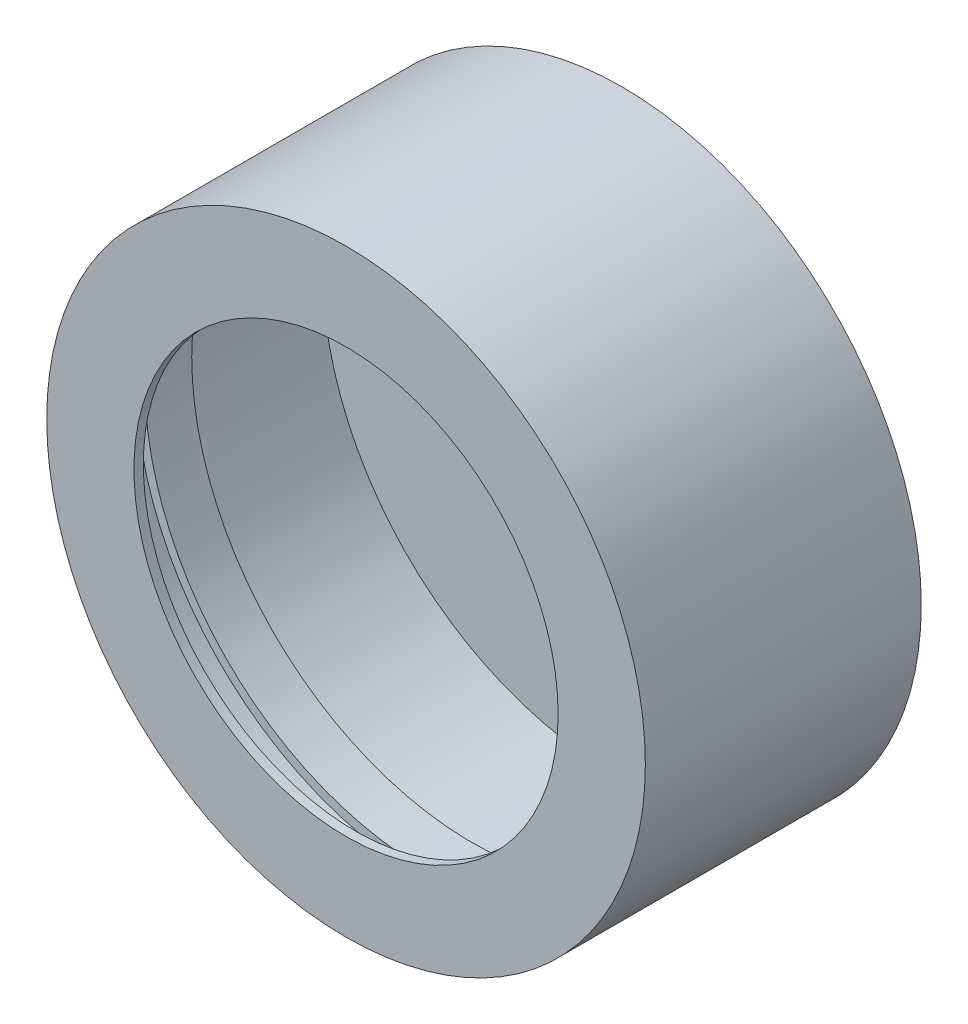
from build123d import *

# Parameters (mm, degrees)
SKETCH1_R           = 64
SKETCH1_R_2         = 62
BOSS_EXTRUDE1_DEPTH = 55
SKETCH2_R           = 62
SKETCH2_R_2         = 60
BOSS_EXTRUDE2_DEPTH = 10
SKETCH3_R           = 64
SKETCH3_R_2         = 45.35
BOSS_EXTRUDE3_DEPTH = 2
SKETCH4_R           = 64
SKETCH4_R_2         = 29
BOSS_EXTRUDE4_DEPTH = 2


with BuildPart() as part:
    # Sketch1 → Boss-Extrude1 (new body)
    with BuildSketch(Plane.XY):
        Circle(SKETCH1_R)
        Circle(SKETCH1_R_2, mode=Mode.SUBTRACT)
    extrude(amount=-BOSS_EXTRUDE1_DEPTH)

    # Sketch2 → Boss-Extrude2 (add)
    with BuildSketch(Plane(origin=(0, 0, -15), x_dir=(-1, 0, 0), z_dir=(0, 0, -1))):
        Circle(SKETCH2_R)
        Circle(SKETCH2_R_2, mode=Mode.SUBTRACT)
    extrude(amount=BOSS_EXTRUDE2_DEPTH)

    # Sketch3 → Boss-Extrude3 (add)
    with BuildSketch(Plane.XY):
        Circle(SKETCH3_R)
        Circle(SKETCH3_R_2, mode=Mode.SUBTRACT)
    extrude(amount=BOSS_EXTRUDE3_DEPTH)

    # Sketch4 → Boss-Extrude4 (add)
    with BuildSketch(Plane(origin=(0, 0, -55), x_dir=(-1, 0, 0), z_dir=(0, 0, -1))):
        Circle(SKETCH4_R)
        Circle(SKETCH4_R_2, mode=Mode.SUBTRACT)
    extrude(amount=BOSS_EXTRUDE4_DEPTH)


solid = part.part
